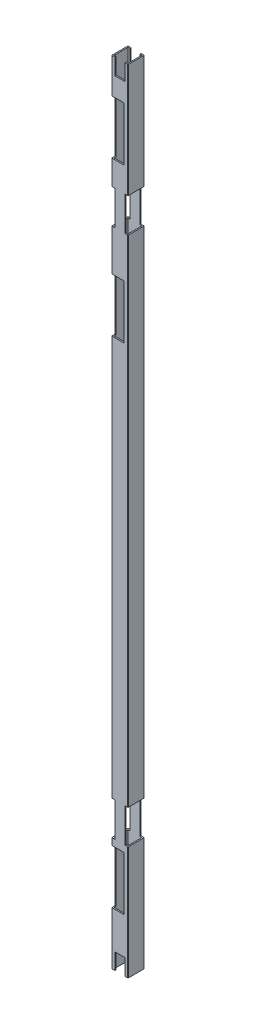
from build123d import *

# Parameters (mm, degrees)
SKETCH1_W           = 17
SKETCH1_H           = 17
BOSS_EXTRUDE1_DEPTH = 975
SKETCH2_W           = 12
SKETCH2_H           = 20
CUT_EXTRUDE1_DEPTH  = 1177
SKETCH3_W           = 4
SKETCH3_H           = 42.2
CUT_EXTRUDE2_DEPTH  = 1177
SKETCH4_R           = 2.1
CUT_EXTRUDE3_DEPTH  = 10
CUT_EXTRUDE4_START  = -20
SKETCH6_W           = 4
SKETCH6_H           = 66.3
CUT_EXTRUDE4_DEPTH  = 15
LPATTERN1_COUNT     = 2
LPATTERN1_PITCH     = 190
LPATTERN2_COUNT     = 2
LPATTERN2_PITCH     = 800


with BuildPart() as part:
    # Sketch1 → Boss-Extrude1 (new body)
    with BuildSketch(Plane(origin=(0, 0, 0), x_dir=(1, 0, 0), z_dir=(0, 1, 0))):
        with BuildLine():
            Line((0.5, 0), (19.5, 0))
            ThreePointArc((19.5, 0), (19.853553391, 0.146446609), (20, 0.5))
            Line((20, 0.5), (20, 19.5))
            ThreePointArc((20, 19.5), (19.853553391, 19.853553391), (19.5, 20))
            Line((19.5, 20), (0.5, 20))
            ThreePointArc((0.5, 20), (0.146446609, 19.853553391), (0, 19.5))
            Line((0, 19.5), (0, 0.5))
            ThreePointArc((0, 0.5), (0.146446609, 0.146446609), (0.5, 0))
        make_face()
        with Locations((10, 10)):
            Rectangle(SKETCH1_W, SKETCH1_H, mode=Mode.SUBTRACT)
    extrude(amount=BOSS_EXTRUDE1_DEPTH)

    # Sketch2 → Cut-Extrude1 (cut)
    with BuildSketch(Plane.XY):
        with Locations((10, 965)):
            Rectangle(SKETCH2_W, SKETCH2_H)
    cut_extrude1 = extrude(amount=-CUT_EXTRUDE1_DEPTH, mode=Mode.SUBTRACT)

    # Sketch3 → Cut-Extrude2 (cut)
    with BuildSketch(Plane(origin=(0, 0, -20), x_dir=(-1, 0, 0), z_dir=(0, 0, -1))):
        with Locations((-2, 813.9)):
            Rectangle(SKETCH3_W, SKETCH3_H)
        with Locations((-18, 813.9)):
            Rectangle(SKETCH3_W, SKETCH3_H)
    cut_extrude2 = extrude(amount=-CUT_EXTRUDE2_DEPTH, mode=Mode.SUBTRACT)

    # Mirror1: Cut-Extrude1, Cut-Extrude2 across plane
    add(cut_extrude1.mirror(Plane.ZX.offset(487.5)), mode=Mode.SUBTRACT)
    add(cut_extrude2.mirror(Plane.ZX.offset(487.5)), mode=Mode.SUBTRACT)

    # Sketch4 → Cut-Extrude3 (cut)
    with BuildSketch(Plane.XY.offset(-20)):
        with Locations((7.75, 921.65)):
            Circle(SKETCH4_R)
        with Locations((7.75, 875.35)):
            Circle(SKETCH4_R)
    cut_extrude3 = extrude(amount=CUT_EXTRUDE3_DEPTH, mode=Mode.SUBTRACT)

    # Sketch6 → Cut-Extrude4 (cut)
    with BuildSketch(Plane(origin=(20, 0, 0), x_dir=(0, 0, -1), z_dir=(1, 0, 0)).offset(CUT_EXTRUDE4_START)):
        with Locations((2, 898.5)):
            Rectangle(SKETCH6_W, SKETCH6_H)
    cut_extrude4 = extrude(amount=CUT_EXTRUDE4_DEPTH, mode=Mode.SUBTRACT)

    # LPattern1: Cut-Extrude3, Cut-Extrude4 ×2
    with Locations(*[(0, -i * LPATTERN1_PITCH, 0) for i in range(1, LPATTERN1_COUNT)]):
        add(cut_extrude3, mode=Mode.SUBTRACT)
        add(cut_extrude4, mode=Mode.SUBTRACT)

    # LPattern2: Cut-Extrude3, Cut-Extrude4 ×2
    with Locations(*[(0, -i * LPATTERN2_PITCH, 0) for i in range(1, LPATTERN2_COUNT)]):
        add(cut_extrude3, mode=Mode.SUBTRACT)
        add(cut_extrude4, mode=Mode.SUBTRACT)


solid = part.part
